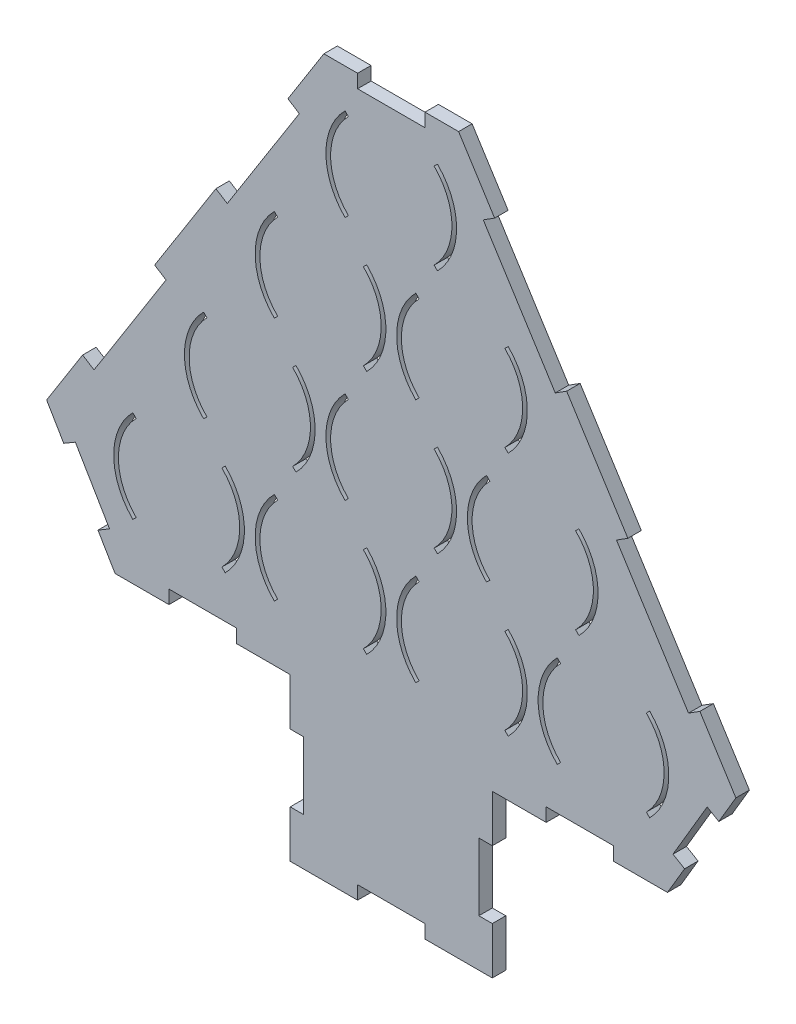
from build123d import *

# Parameters (mm, degrees)
BOSS_EXTRU_1_DEPTH      = 10
ESQUISSE2_W             = 150
ESQUISSE2_H             = 120
BOSS_EXTRU_2_DEPTH      = 10
ESQUISSE3_W             = 10
ESQUISSE3_H             = 50
ESQUISSE3_W_2           = 50
ESQUISSE3_H_2           = 10
ENL_V_MAT_EXTRU_1_DEPTH = 10
ESQUISSE4_W             = 50
ESQUISSE4_H             = 10
ENL_V_MAT_EXTRU_2_DEPTH = 10


with BuildPart() as part:
    # Esquisse1 → Boss.-Extru.1 (new body)
    with BuildSketch(Plane.XY):
        Polygon((-50, 335.901139535), (50, 335.901139535), (255.775862069, 10.507079064), (205, -75.642859016), (-205, -75.642859016), (-255.775862069, 10.507079064), align=None)
        with BuildLine():
            Line((-189.319805153, 31.819805153), (-191.794678888, 34.294678888))
            ThreePointArc((-191.794678888, 34.294678888), (-206, 0), (-191.794678888, -34.294678888))
            Line((-191.794678888, -34.294678888), (-189.319805153, -31.819805153))
            ThreePointArc((-189.319805153, -31.819805153), (-202.5, 0), (-189.319805153, 31.819805153))
        make_face(mode=Mode.SUBTRACT)
        with BuildLine():
            Line((-125.680194847, 31.819805153), (-123.205321112, 34.294678888))
            ThreePointArc((-123.205321112, 34.294678888), (-109, 0), (-123.205321112, -34.294678888))
            Line((-123.205321112, -34.294678888), (-125.680194847, -31.819805153))
            ThreePointArc((-125.680194847, -31.819805153), (-112.5, 0), (-125.680194847, 31.819805153))
        make_face(mode=Mode.SUBTRACT)
        with BuildLine():
            Line((-84.319805153, -31.819805153), (-86.794678888, -34.294678888))
            ThreePointArc((-86.794678888, -34.294678888), (-101, 0), (-86.794678888, 34.294678888))
            Line((-86.794678888, 34.294678888), (-84.319805153, 31.819805153))
            ThreePointArc((-84.319805153, 31.819805153), (-97.5, 0), (-84.319805153, -31.819805153))
        make_face(mode=Mode.SUBTRACT)
        with BuildLine():
            Line((-20.680194847, 31.819805153), (-18.205321112, 34.294678888))
            ThreePointArc((-18.205321112, 34.294678888), (-4, 0), (-18.205321112, -34.294678888))
            Line((-18.205321112, -34.294678888), (-20.680194847, -31.819805153))
            ThreePointArc((-20.680194847, -31.819805153), (-7.5, 0), (-20.680194847, 31.819805153))
        make_face(mode=Mode.SUBTRACT)
        with BuildLine():
            Line((20.680194847, -31.819805153), (18.205321112, -34.294678888))
            ThreePointArc((18.205321112, -34.294678888), (4, 0), (18.205321112, 34.294678888))
            Line((18.205321112, 34.294678888), (20.680194847, 31.819805153))
            ThreePointArc((20.680194847, 31.819805153), (7.5, 0), (20.680194847, -31.819805153))
        make_face(mode=Mode.SUBTRACT)
        with BuildLine():
            Line((84.319805153, 31.819805153), (86.794678888, 34.294678888))
            ThreePointArc((86.794678888, 34.294678888), (101, 0), (86.794678888, -34.294678888))
            Line((86.794678888, -34.294678888), (84.319805153, -31.819805153))
            ThreePointArc((84.319805153, -31.819805153), (97.5, 0), (84.319805153, 31.819805153))
        make_face(mode=Mode.SUBTRACT)
        with BuildLine():
            Line((125.680194847, -31.819805153), (123.205321112, -34.294678888))
            ThreePointArc((123.205321112, -34.294678888), (109, 0), (123.205321112, 34.294678888))
            Line((123.205321112, 34.294678888), (125.680194847, 31.819805153))
            ThreePointArc((125.680194847, 31.819805153), (112.5, 0), (125.680194847, -31.819805153))
        make_face(mode=Mode.SUBTRACT)
        with BuildLine():
            Line((189.319805153, 31.819805153), (191.794678888, 34.294678888))
            ThreePointArc((191.794678888, 34.294678888), (206, 0), (191.794678888, -34.294678888))
            Line((191.794678888, -34.294678888), (189.319805153, -31.819805153))
            ThreePointArc((189.319805153, -31.819805153), (202.5, 0), (189.319805153, 31.819805153))
        make_face(mode=Mode.SUBTRACT)
        with BuildLine():
            Line((-139.294678888, 56.63798851), (-136.819805153, 59.112862244))
            ThreePointArc((-136.819805153, 59.112862244), (-150, 90.932667397), (-136.819805153, 122.752472551))
            Line((-136.819805153, 122.752472551), (-139.294678888, 125.227346285))
            ThreePointArc((-139.294678888, 125.227346285), (-153.5, 90.932667397), (-139.294678888, 56.63798851))
        make_face(mode=Mode.SUBTRACT)
        with BuildLine():
            Line((-70.705321112, 56.63798851), (-73.180194847, 59.112862244))
            ThreePointArc((-73.180194847, 59.112862244), (-60, 90.932667397), (-73.180194847, 122.752472551))
            Line((-73.180194847, 122.752472551), (-70.705321112, 125.227346285))
            ThreePointArc((-70.705321112, 125.227346285), (-56.5, 90.932667397), (-70.705321112, 56.63798851))
        make_face(mode=Mode.SUBTRACT)
        with BuildLine():
            Line((-31.819805153, 122.752472551), (-34.294678888, 125.227346285))
            ThreePointArc((-34.294678888, 125.227346285), (-48.5, 90.932667397), (-34.294678888, 56.63798851))
            Line((-34.294678888, 56.63798851), (-31.819805153, 59.112862244))
            ThreePointArc((-31.819805153, 59.112862244), (-45, 90.932667397), (-31.819805153, 122.752472551))
        make_face(mode=Mode.SUBTRACT)
        with BuildLine():
            Line((34.294678888, 56.63798851), (31.819805153, 59.112862244))
            ThreePointArc((31.819805153, 59.112862244), (45, 90.932667397), (31.819805153, 122.752472551))
            Line((31.819805153, 122.752472551), (34.294678888, 125.227346285))
            ThreePointArc((34.294678888, 125.227346285), (48.5, 90.932667397), (34.294678888, 56.63798851))
        make_face(mode=Mode.SUBTRACT)
        with BuildLine():
            Line((73.180194847, 122.752472551), (70.705321112, 125.227346285))
            ThreePointArc((70.705321112, 125.227346285), (56.5, 90.932667397), (70.705321112, 56.63798851))
            Line((70.705321112, 56.63798851), (73.180194847, 59.112862244))
            ThreePointArc((73.180194847, 59.112862244), (60, 90.932667397), (73.180194847, 122.752472551))
        make_face(mode=Mode.SUBTRACT)
        with BuildLine():
            Line((139.294678888, 56.63798851), (136.819805153, 59.112862244))
            ThreePointArc((136.819805153, 59.112862244), (150, 90.932667397), (136.819805153, 122.752472551))
            Line((136.819805153, 122.752472551), (139.294678888, 125.227346285))
            ThreePointArc((139.294678888, 125.227346285), (153.5, 90.932667397), (139.294678888, 56.63798851))
        make_face(mode=Mode.SUBTRACT)
        with BuildLine():
            Line((-84.319805153, 213.685139948), (-86.794678888, 216.160013682))
            ThreePointArc((-86.794678888, 216.160013682), (-101, 181.865334795), (-86.794678888, 147.570655907))
            Line((-86.794678888, 147.570655907), (-84.319805153, 150.045529641))
            ThreePointArc((-84.319805153, 150.045529641), (-97.5, 181.865334795), (-84.319805153, 213.685139948))
        make_face(mode=Mode.SUBTRACT)
        with BuildLine():
            Line((-20.680194847, 213.685139948), (-18.205321112, 216.160013682))
            ThreePointArc((-18.205321112, 216.160013682), (-4, 181.865334795), (-18.205321112, 147.570655907))
            Line((-18.205321112, 147.570655907), (-20.680194847, 150.045529641))
            ThreePointArc((-20.680194847, 150.045529641), (-7.5, 181.865334795), (-20.680194847, 213.685139948))
        make_face(mode=Mode.SUBTRACT)
        with BuildLine():
            Line((20.680194847, 150.045529641), (18.205321112, 147.570655907))
            ThreePointArc((18.205321112, 147.570655907), (4, 181.865334795), (18.205321112, 216.160013682))
            Line((18.205321112, 216.160013682), (20.680194847, 213.685139948))
            ThreePointArc((20.680194847, 213.685139948), (7.5, 181.865334795), (20.680194847, 150.045529641))
        make_face(mode=Mode.SUBTRACT)
        with BuildLine():
            Line((84.319805153, 150.045529641), (86.794678888, 147.570655907))
            ThreePointArc((86.794678888, 147.570655907), (101, 181.865334795), (86.794678888, 216.160013682))
            Line((86.794678888, 216.160013682), (84.319805153, 213.685139948))
            ThreePointArc((84.319805153, 213.685139948), (97.5, 181.865334795), (84.319805153, 150.045529641))
        make_face(mode=Mode.SUBTRACT)
        with BuildLine():
            Line((-31.819805153, 304.617807345), (-34.294678888, 307.09268108))
            ThreePointArc((-34.294678888, 307.09268108), (-48.5, 272.798002192), (-34.294678888, 238.503323305))
            Line((-34.294678888, 238.503323305), (-31.819805153, 240.978197039))
            ThreePointArc((-31.819805153, 240.978197039), (-45, 272.798002192), (-31.819805153, 304.617807345))
        make_face(mode=Mode.SUBTRACT)
        with BuildLine():
            Line((31.819805153, 304.617807345), (34.294678888, 307.09268108))
            ThreePointArc((34.294678888, 307.09268108), (48.5, 272.798002192), (34.294678888, 238.503323305))
            Line((34.294678888, 238.503323305), (31.819805153, 240.978197039))
            ThreePointArc((31.819805153, 240.978197039), (45, 272.798002192), (31.819805153, 304.617807345))
        make_face(mode=Mode.SUBTRACT)
    extrude(amount=BOSS_EXTRU_1_DEPTH)

    # Esquisse2 → Boss.-Extru.2 (add)
    with BuildSketch(Plane.XY.offset(10)):
        with Locations((0, -135.642859016)):
            Rectangle(ESQUISSE2_W, ESQUISSE2_H)
    extrude(amount=-BOSS_EXTRU_2_DEPTH)

    # Esquisse3 → Enlèv. mat.-Extru.1 (cut)
    with BuildSketch(Plane.XY.offset(10)):
        with Locations((-70, -135.642859016)):
            Rectangle(ESQUISSE3_W, ESQUISSE3_H)
        with Locations((0, -190.642859016)):
            Rectangle(ESQUISSE3_W_2, ESQUISSE3_H_2)
        with Locations((70, -135.642859016)):
            Rectangle(ESQUISSE3_W, ESQUISSE3_H)
    extrude(amount=-ENL_V_MAT_EXTRU_1_DEPTH, mode=Mode.SUBTRACT)

    # Esquisse4 → Enlèv. mat.-Extru.2 (cut)
    with BuildSketch(Plane.XY.offset(10)):
        with Locations((-140, -70.642859016)):
            Rectangle(ESQUISSE4_W, ESQUISSE4_H)
        Polygon((-217.693965517, -54.105374496), (-209.078971709, -49.027788289), (-234.466902744, -5.952819249), (-243.081896552, -11.030405456), align=None)
        Polygon((-229.051724138, 52.766047956), (-220.599930359, 47.42122037), (-167.151654497, 131.939158154), (-175.603448276, 137.283985741), align=None)
        Polygon((-68.272344153, 288.297343056), (-76.724137931, 293.642170642), (-130.172413793, 209.124232858), (-121.720620015, 203.779405271), align=None)
        with Locations((0, 330.901139535)):
            Rectangle(ESQUISSE4_W, ESQUISSE4_H)
        with Locations((140, -70.642859016)):
            Rectangle(ESQUISSE4_W, ESQUISSE4_H)
        Polygon((234.466902744, -5.952819249), (243.081896552, -11.030405456), (217.693965517, -54.105374496), (209.078971709, -49.027788289), align=None)
        Polygon((167.151654497, 131.939158154), (175.603448276, 137.283985741), (229.051724138, 52.766047956), (220.599930359, 47.42122037), align=None)
        Polygon((121.720620015, 203.779405271), (130.172413793, 209.124232858), (76.724137931, 293.642170642), (68.272344153, 288.297343056), align=None)
    extrude(amount=-ENL_V_MAT_EXTRU_2_DEPTH, mode=Mode.SUBTRACT)


solid = part.part
